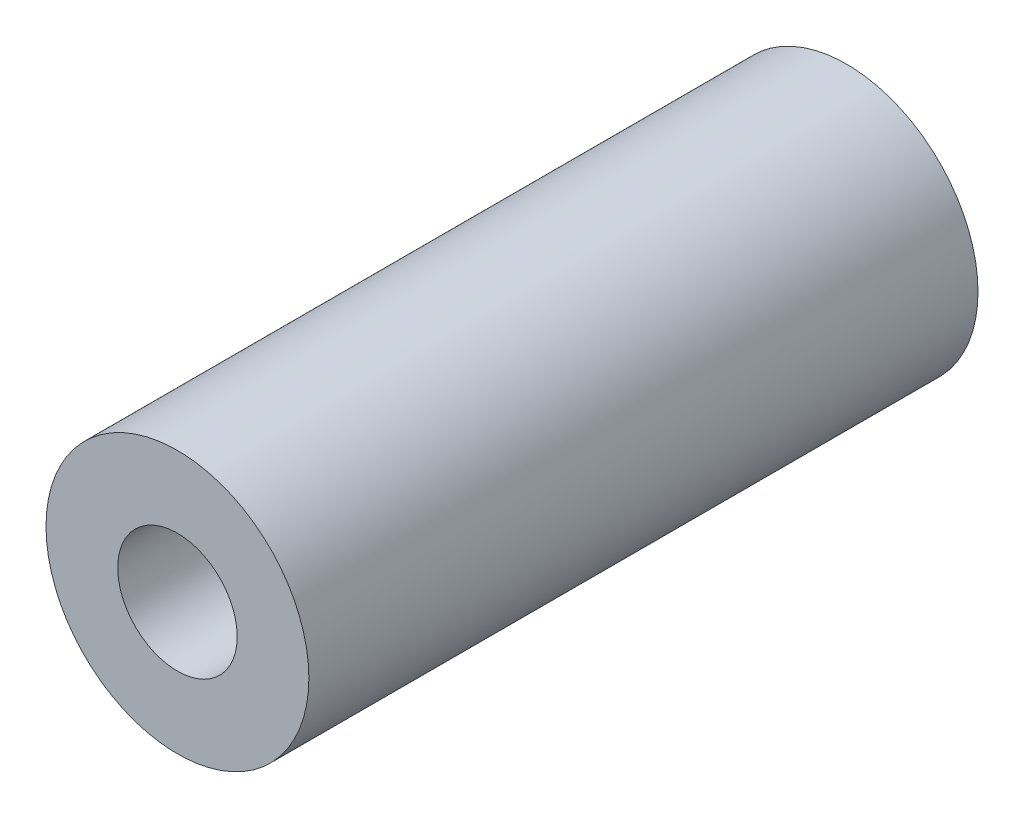
from build123d import *

# Parameters (mm, degrees)
CROQUIS1_R              = 11
CROQUIS1_W              = 12
CROQUIS1_H              = 10
SALIENTE_EXTRUIR1_DEPTH = 26
CROQUIS3_R              = 11
CROQUIS3_R_2            = 8
SALIENTE_EXTRUIR2_DEPTH = 30
CROQUIS5_R              = 11
CROQUIS5_R_2            = 5
SALIENTE_EXTRUIR3_DEPTH = 15


with BuildPart() as part:
    # Croquis1 → Saliente-Extruir1 (new body)
    with BuildSketch(Plane.XY):
        Circle(CROQUIS1_R)
        Rectangle(CROQUIS1_W, CROQUIS1_H, mode=Mode.SUBTRACT)
    extrude(amount=SALIENTE_EXTRUIR1_DEPTH)

    # Croquis3 → Saliente-Extruir2 (add)
    with BuildSketch(Plane.XY.offset(26)):
        Circle(CROQUIS3_R)
        Circle(CROQUIS3_R_2, mode=Mode.SUBTRACT)
    extrude(amount=SALIENTE_EXTRUIR2_DEPTH)

    # Croquis5 → Saliente-Extruir3 (add)
    with BuildSketch(Plane.XY.offset(56)):
        Circle(CROQUIS5_R)
        Circle(CROQUIS5_R_2, mode=Mode.SUBTRACT)
    extrude(amount=-SALIENTE_EXTRUIR3_DEPTH)


solid = part.part
